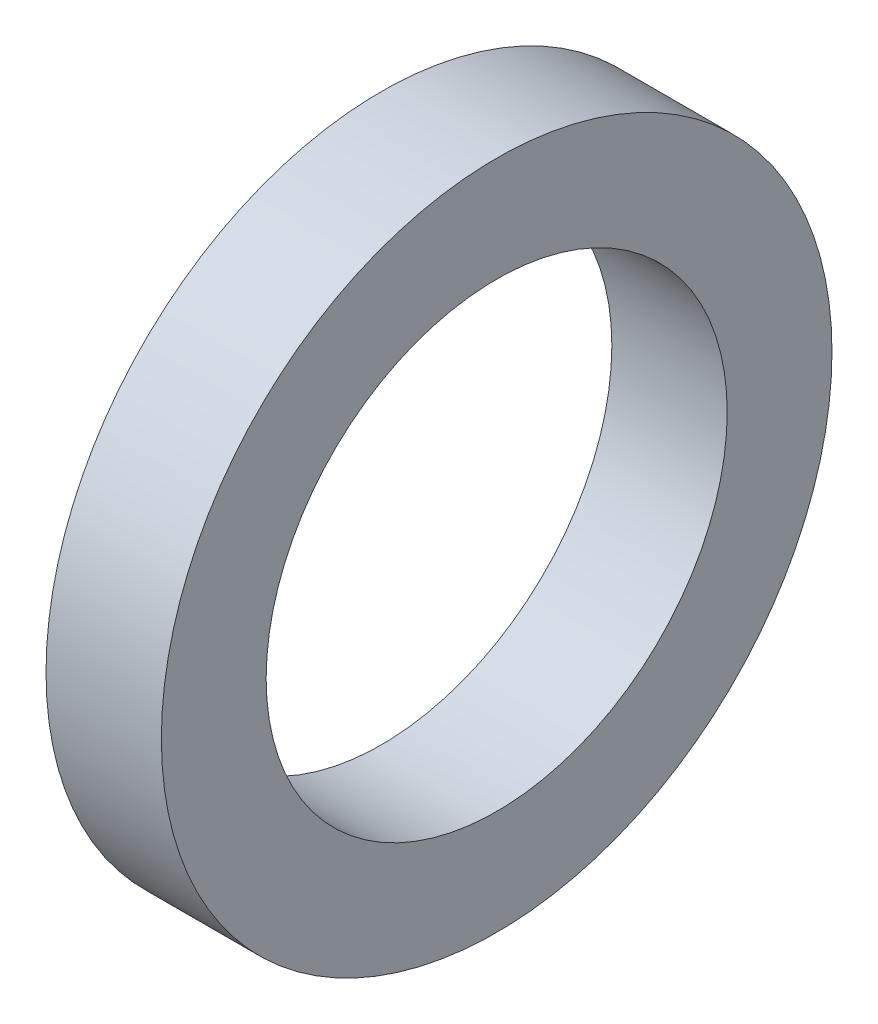
from build123d import *

# Parameters (mm, degrees)
SKETCH1_R                   = 25.4
BOSS_EXTRUDE1_DEPTH         = 8.7376
F_97_1_375_DIAMETER_HOLE1_D = 34.925


with BuildPart() as part:
    # Sketch1 → Boss-Extrude1 (new body)
    with BuildSketch(Plane(origin=(0, 0, 0), x_dir=(0, 0, -1), z_dir=(1, 0, 0))):
        Circle(SKETCH1_R)
    extrude(amount=BOSS_EXTRUDE1_DEPTH)

    # #97 (1.375) Diameter Hole1 (through all)
    with Locations(Plane(origin=(8.7376, 0, 0), x_dir=(0, 0, -1), z_dir=(1, 0, 0))):
        with Locations((0, 0)):
            Hole(F_97_1_375_DIAMETER_HOLE1_D / 2)


solid = part.part
